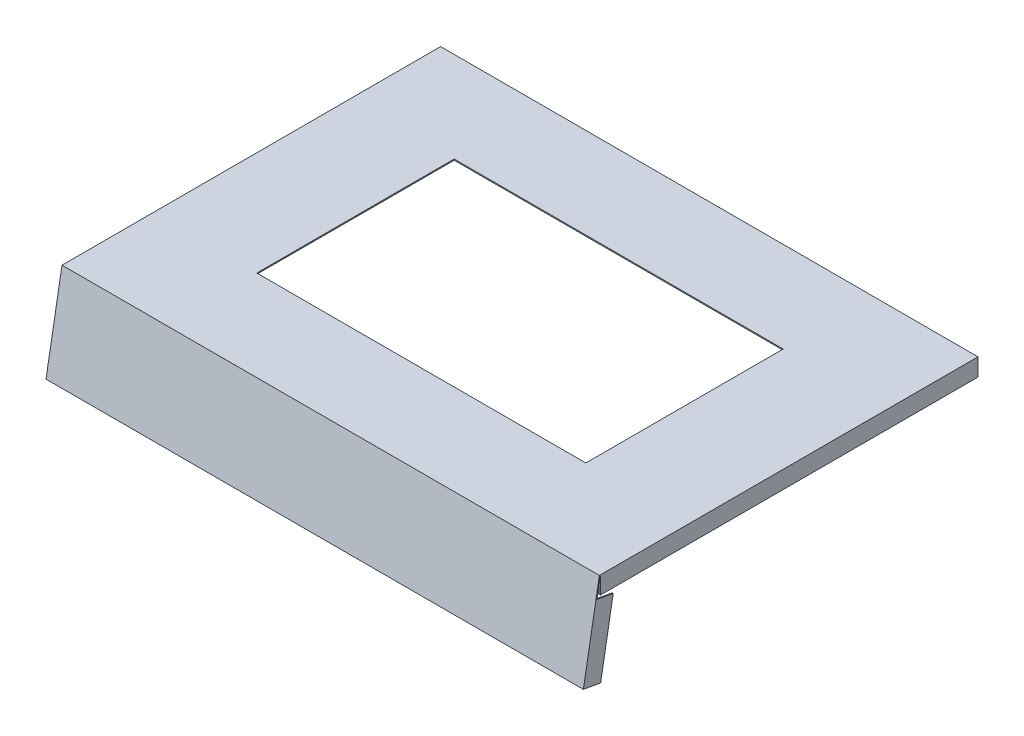
from build123d import *

# Parameters (mm, degrees)
CROQUIS1_W              = 490
CROQUIS1_H              = 345.25
SALIENTE_EXTRUIR1_DEPTH = 1
CROQUIS2_W              = 300
CROQUIS2_H              = 180
CORTAR_EXTRUIR1_DEPTH   = 2
SALIENTE_EXTRUIR2_DEPTH = 490
SALIENTE_EXTRUIR3_DEPTH = 15
SALIENTE_EXTRUIR4_DEPTH = 15
CROQUIS6_R              = 1.5
SALIENTE_EXTRUIR5_DEPTH = 3


with BuildPart() as part:
    # Croquis1 → Saliente-Extruir1 (new body)
    with BuildSketch(Plane(origin=(0, 0, 0), x_dir=(1, 0, 0), z_dir=(0, 1, 0))):
        Rectangle(CROQUIS1_W, CROQUIS1_H)
    extrude(amount=SALIENTE_EXTRUIR1_DEPTH)

    # Croquis2 → Cortar-Extruir1 (cut, through all)
    with BuildSketch(Plane(origin=(0, 1, 0), x_dir=(1, 0, 0), z_dir=(0, 1, 0))):
        Rectangle(CROQUIS2_W, CROQUIS2_H)
    extrude(amount=-CORTAR_EXTRUIR1_DEPTH, mode=Mode.SUBTRACT)

    # Croquis3 → Saliente-Extruir2 (add, through all)
    with BuildSketch(Plane(origin=(245, 0, 0), x_dir=(0, 0, -1), z_dir=(1, 0, 0))):
        Polygon((-172.625, 1), (-187.211446924, -81.723851253), (-186.226639171, -81.897499431), (-171.609573388, 1), align=None)
    extrude(amount=-SALIENTE_EXTRUIR2_DEPTH)

    # Croquis4 → Saliente-Extruir3 (add)
    with BuildSketch(Plane.XZ):
        Polygon((-245, -172.625), (-245, 171.785900369), (-244, 171.785900369), (-244, -171.625), (244, -171.625), (244, 171.785900369), (245, 171.785900369), (245, -172.625), align=None)
    extrude(amount=SALIENTE_EXTRUIR3_DEPTH)

    # Croquis5 → Saliente-Extruir4 (add)
    with BuildSketch(Plane(origin=(0, 29.377119133, 166.60592165), x_dir=(-1, 0, 0), z_dir=(0, -0.173648178, -0.984807753))):
        Polygon((-244, -111.991208917), (-244, -46.991208917), (-245, -46.991208917), (-245, -112.991208917), (245, -112.991208917), (245, -46.991208917), (244, -46.991208917), (244, -111.991208917), align=None)
    extrude(amount=SALIENTE_EXTRUIR4_DEPTH)

    # Croquis6 → Saliente-Extruir5 (add)
    with BuildSketch(Plane.ZY.offset(245)):
        with Locations((-166.625, -7)):
            Circle(CROQUIS6_R)
    extrude(amount=SALIENTE_EXTRUIR5_DEPTH)


solid = part.part
